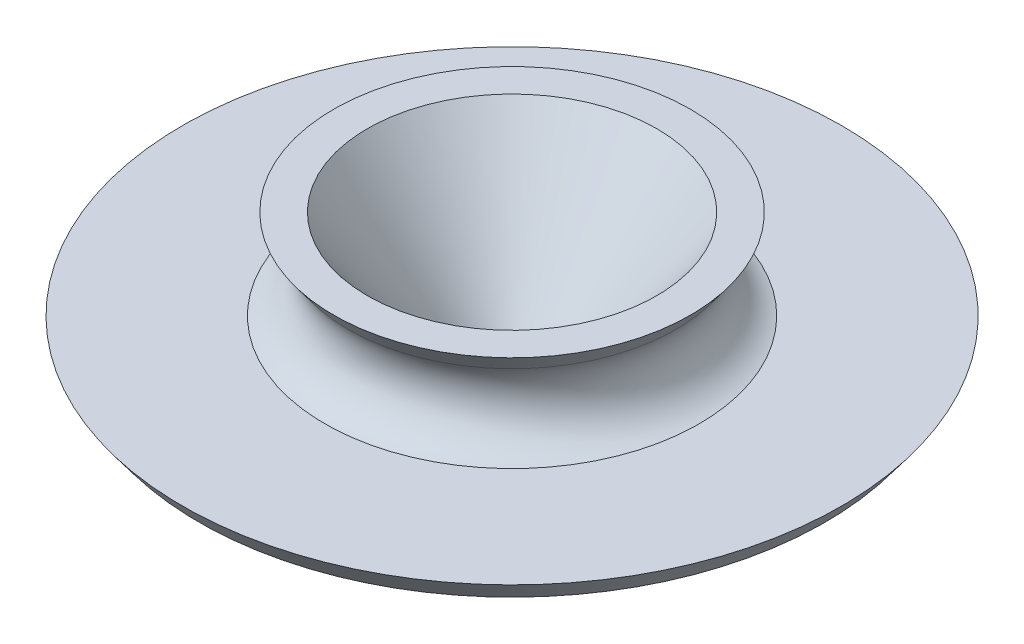
from build123d import *


with BuildPart() as part:
    # Sketch1 → Revolve1 (revolve)
    with BuildSketch(Plane.XY):
        with BuildLine():
            Line((-0.915133072, -47.682722084), (-21.935744519, -47.682722084))
            Line((-21.935744519, -47.682722084), (-26.646227047, -41.332722084))
            Line((-26.646227047, -41.332722084), (-76.783206885, -41.332722084))
            Line((-76.783206885, -41.332722084), (-81.493689413, -34.982722084))
            Line((-81.493689413, -34.982722084), (-41.186438296, -34.982722084))
            ThreePointArc((-41.186438296, -34.982722084), (-32.688024732, -26.842579107), (-34.522388815, -15.218463262))
            Line((-34.522388815, -15.218463262), (-38.70302824, -9.582722084))
            Line((-38.70302824, -9.582722084), (-29.17802824, -9.582722084))
            Line((-29.17802824, -9.582722084), (-0.915133072, -47.682722084))
        make_face()
    revolve(axis=Axis((11.784866928, -49.703724191, 0), (0, 1, 0)))


solid = part.part
